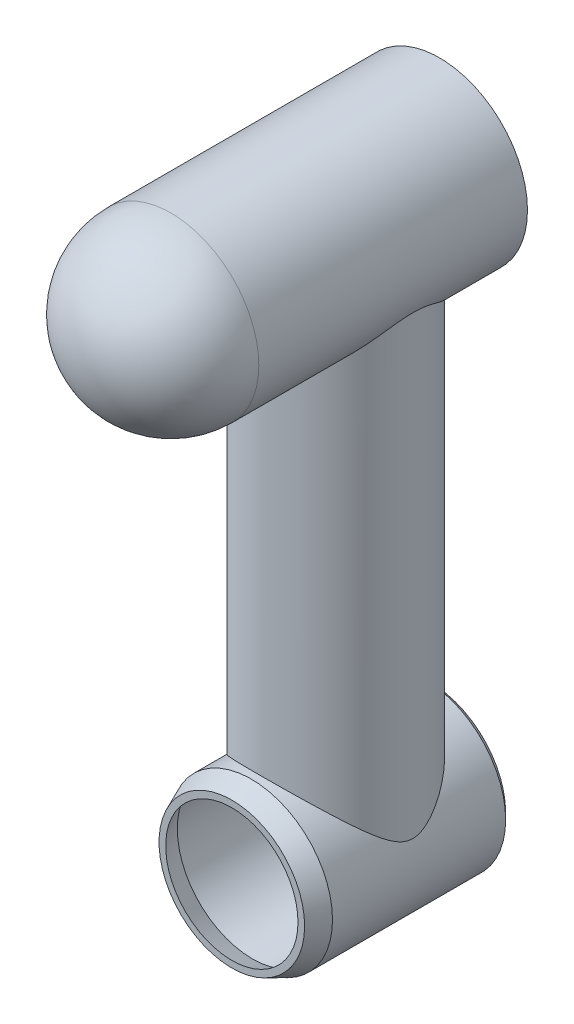
from build123d import *

# Parameters (mm, degrees)
SKETCH1_R                = 72.5
BOSS_EXTRUDE1_DEPTH      = 294
FILLET1_R                = 72.5
SKETCH2_R                = 63.5
BOSS_EXTRUDE2_DEPTH      = 431.8
BOSS_EXTRUDE3_DEPTH      = 85.75
BOSS_EXTRUDE3_DEPTH_BACK = 78
SKETCH3_R                = 67
CHAMFER1_SIZE            = 5
CHAMFER2_SIZE            = 16
CHAMFER2_SIZE2           = 7
SHELL1_T                 = -5


with BuildPart() as part:
    # Sketch1 → Boss-Extrude1 (new body)
    with BuildSketch(Plane.XY):
        Circle(SKETCH1_R)
    extrude(amount=BOSS_EXTRUDE1_DEPTH)

    # Fillet1
    fillet1_edges = [part.edges().sort_by_distance(p)[0] for p in [
        (-72.5, 0, 294),
    ]]
    fillet(fillet1_edges, radius=FILLET1_R)

    # Sketch2 → Boss-Extrude2 (add)
    with BuildSketch(Plane(origin=(0, 0, 0), x_dir=(1, 0, 0), z_dir=(0, 1, 0))):
        with Locations((0, -85.5)):
            Circle(SKETCH2_R)
    extrude(amount=-BOSS_EXTRUDE2_DEPTH)

    # Sketch3 → Boss-Extrude3 (add, two sides: drawn at the far end of the back side and taken through both)
    with BuildSketch(Plane.XY.offset(85.5).offset(-BOSS_EXTRUDE3_DEPTH_BACK)):
        with Locations((0, -431.8)):
            Circle(SKETCH3_R)
    extrude(amount=BOSS_EXTRUDE3_DEPTH + BOSS_EXTRUDE3_DEPTH_BACK)

    # Chamfer1
    chamfer1_edges = [part.edges().sort_by_distance(p)[0] for p in [
        (-67, -431.8, 7.5),
    ]]
    chamfer(chamfer1_edges, length=CHAMFER1_SIZE)

    # Chamfer2
    chamfer2_edges = [part.edges().sort_by_distance(p)[0] for p in [
        (-67, -431.8, 171.25),
    ]]
    chamfer2_side = [part.faces().sort_by_distance(p)[0] for p in [
        (-67, -431.8, 91.875),
    ]]
    chamfer(chamfer2_edges, length=CHAMFER2_SIZE, length2=CHAMFER2_SIZE2, reference=chamfer2_side[0])

    # Shell1
    shell1_openings = [part.faces().sort_by_distance(p)[0] for p in [
        (0, -431.8, 171.25),
        (0, 0, 0),
    ]]
    offset(amount=SHELL1_T, openings=shell1_openings, kind=Kind.INTERSECTION)


solid = part.part
